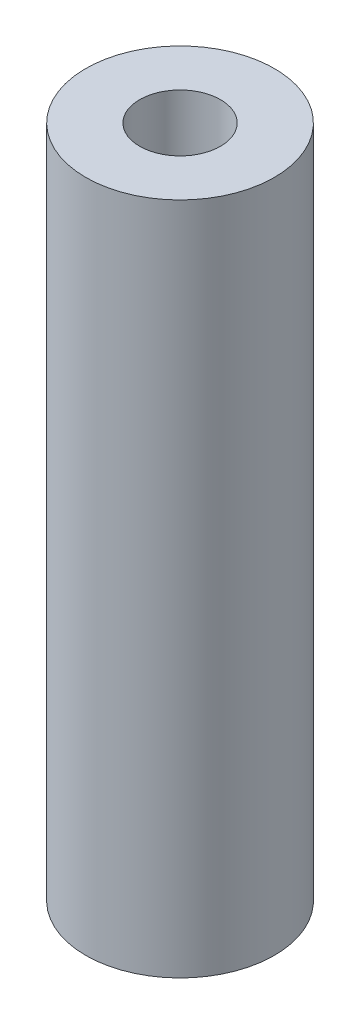
from build123d import *

# Parameters (mm, degrees)
SKETCH_1_R      = 3.5
SKETCH_1_R_2    = 1.5
EXTRUDE_1_DEPTH = 25


with BuildPart() as part:
    # Эскиз1 → Бобышка-Вытянуть1 (new body)
    with BuildSketch(Plane(origin=(0, 0, 0), x_dir=(1, 0, 0), z_dir=(0, 1, 0))):
        with Locations((-2.293103448, 1.342672414)):
            Circle(SKETCH_1_R)
        with Locations((-2.293103448, 1.342672414)):
            Circle(SKETCH_1_R_2, mode=Mode.SUBTRACT)
    extrude(amount=EXTRUDE_1_DEPTH)


solid = part.part
